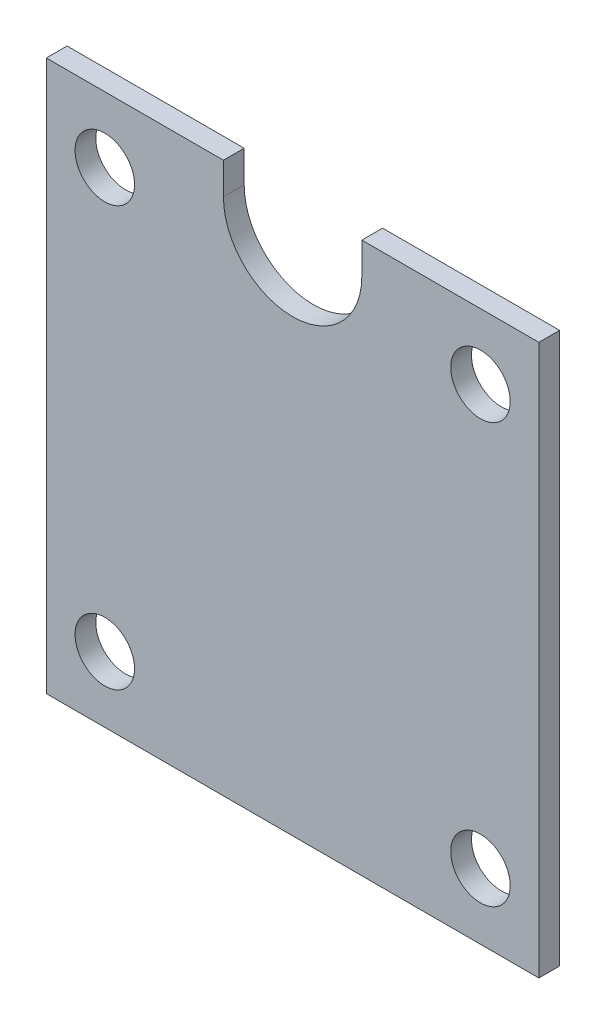
from build123d import *

# Parameters (mm, degrees)
SKETCH1_R           = 4.3
BOSS_EXTRUDE1_DEPTH = 3


with BuildPart() as part:
    # Sketch1 → Boss-Extrude1 (new body)
    with BuildSketch(Plane.XY):
        with BuildLine():
            Line((-35.59279418, 39.784944199), (-35.59279418, -39.784944199))
            Line((-35.59279418, -39.784944199), (35.59279418, -39.784944199))
            Line((35.59279418, -39.784944199), (35.59279418, 39.784944199))
            Line((35.59279418, 39.784944199), (10, 39.784944199))
            Line((10, 39.784944199), (10, 35.2))
            ThreePointArc((10, 35.2), (0, 25.2), (-10, 35.2))
            Line((-10, 35.2), (-10, 39.784944199))
            Line((-10, 39.784944199), (-35.59279418, 39.784944199))
        make_face()
        with Locations((-27.15, -30.3)):
            Circle(SKETCH1_R, mode=Mode.SUBTRACT)
        with Locations((27.15, -30.3)):
            Circle(SKETCH1_R, mode=Mode.SUBTRACT)
        with Locations((-27.15, 30.3)):
            Circle(SKETCH1_R, mode=Mode.SUBTRACT)
        with Locations((27.15, 30.3)):
            Circle(SKETCH1_R, mode=Mode.SUBTRACT)
    extrude(amount=BOSS_EXTRUDE1_DEPTH)


solid = part.part
